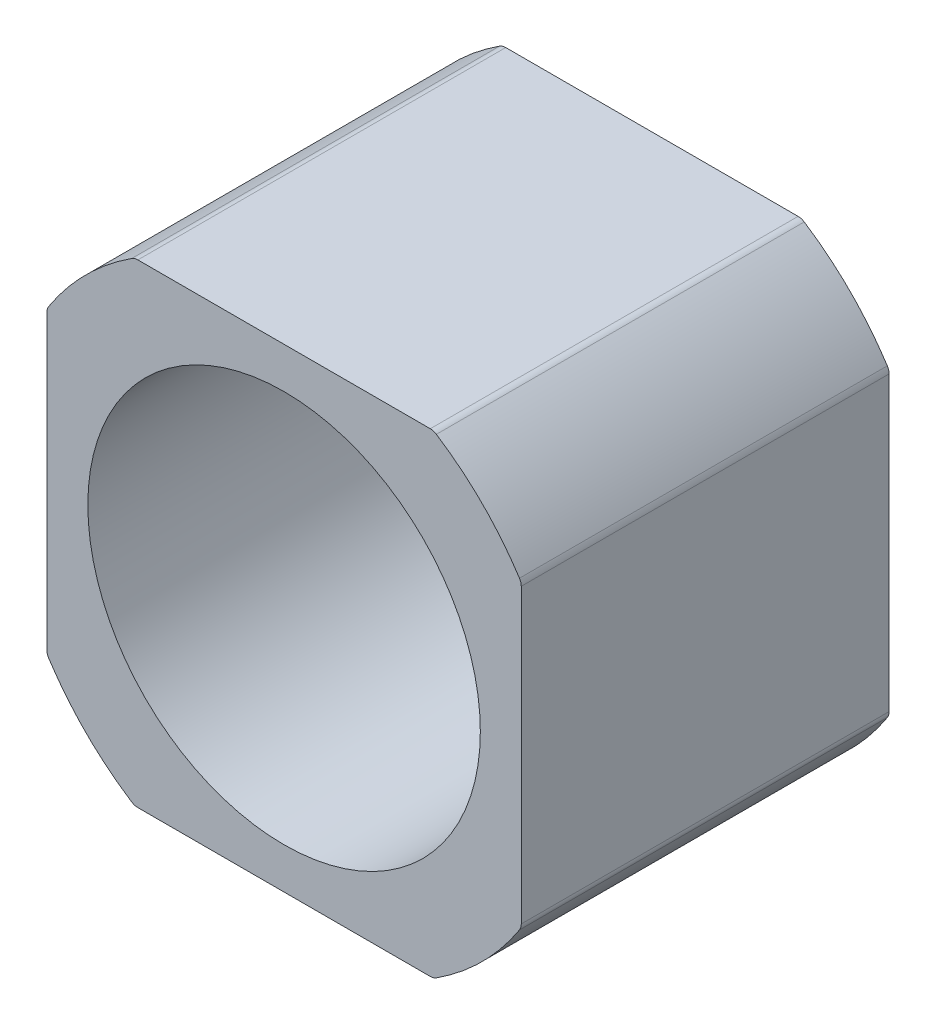
from build123d import *

# Parameters (mm, degrees)
CROQUIS1_W              = 42.3
CROQUIS1_H              = 42.3
SALIENTE_EXTRUIR1_DEPTH = 32.8
SKETCH1_R               = 29.910616844
SKETCH1_R_2             = 25
CUT_EXTRUDE1_DEPTH      = 33.8
FILLET1_R               = 1
SKETCH2_R               = 17.5
CUT_EXTRUDE2_DEPTH      = 33.8


with BuildPart() as part:
    # Croquis1 → Saliente-Extruir1 (new body)
    with BuildSketch(Plane.XY):
        Rectangle(CROQUIS1_W, CROQUIS1_H)
    extrude(amount=SALIENTE_EXTRUIR1_DEPTH)

    # Sketch1 → Cut-Extrude1 (cut, through all)
    with BuildSketch(Plane.XY.offset(32.8)):
        Circle(SKETCH1_R)
        Circle(SKETCH1_R_2, mode=Mode.SUBTRACT)
    extrude(amount=-CUT_EXTRUDE1_DEPTH, mode=Mode.SUBTRACT)

    # Fillet1
    fillet1_edges = [part.edges().sort_by_distance(p)[0] for p in [
        (21.15, -13.329572386, 16.4),
        (21.15, 13.329572386, 16.4),
        (13.329572386, 21.15, 16.4),
        (-13.329572386, 21.15, 16.4),
        (-21.15, 13.329572386, 16.4),
        (-21.15, -13.329572386, 16.4),
        (-13.329572386, -21.15, 16.4),
        (13.329572386, -21.15, 16.4),
    ]]
    fillet(fillet1_edges, radius=FILLET1_R)

    # Sketch2 → Cut-Extrude2 (cut, through all)
    with BuildSketch(Plane.XY.offset(32.8)):
        Circle(SKETCH2_R)
    extrude(amount=-CUT_EXTRUDE2_DEPTH, mode=Mode.SUBTRACT)


solid = part.part
